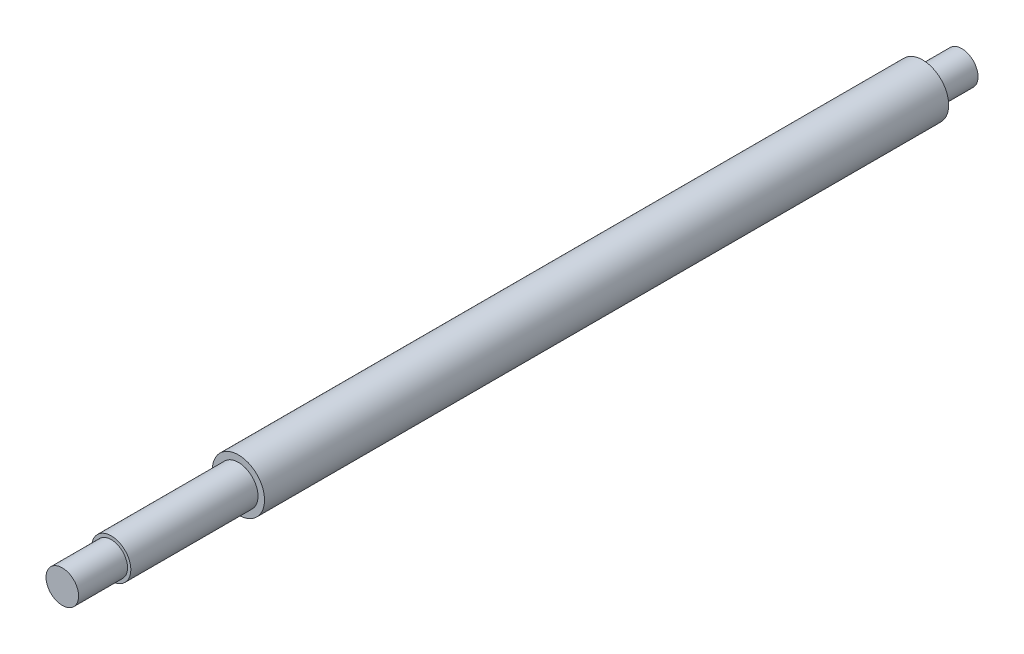
from build123d import *


with BuildPart() as part:
    # Sketch3 → Revolve2 (revolve)
    with BuildSketch(Plane(origin=(0, 0, 0), x_dir=(0, 0, -1), z_dir=(1, 0, 0))):
        Polygon((-275.75, 0), (-275.75, 5), (-260.75, 5), (-260.75, 6), (-221.75, 6), (-221.75, 8), (-12, 8), (-12, 5), (0, 5), (0, 0), align=None)
    revolve(axis=Axis((0, 0, 80.925381137), (0, 0, 1)))


solid = part.part
